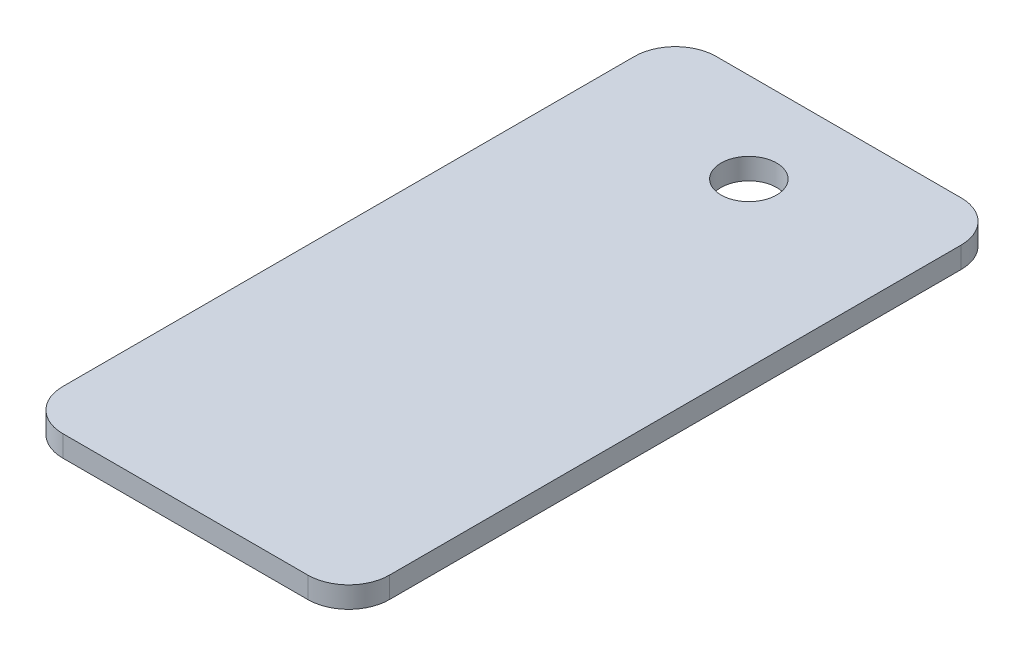
from build123d import *

# Parameters (mm, degrees)
SKETCH1_W                = 20
SKETCH1_H                = 40
BOSS_EXTRUDE1_DEPTH      = 1.3
M3_CLEARANCE_HOLE1_D     = 3.4
M3_CLEARANCE_HOLE1_DEPTH = 1.3
FILLET1_R                = 2.5


with BuildPart() as part:
    # Sketch1 → Boss-Extrude1 (new body)
    with BuildSketch(Plane(origin=(0, 0, 0), x_dir=(1, 0, 0), z_dir=(0, 1, 0))):
        with Locations((10, -20)):
            Rectangle(SKETCH1_W, SKETCH1_H)
    extrude(amount=BOSS_EXTRUDE1_DEPTH)

    # M3 Clearance Hole1
    with Locations(Plane(origin=(0, 1.3, 0), x_dir=(1, 0, 0), z_dir=(0, 1, 0))):
        with Locations((10, -5.5)):
            Hole(M3_CLEARANCE_HOLE1_D / 2, depth=M3_CLEARANCE_HOLE1_DEPTH)

    # Fillet1
    fillet1_edges = [part.edges().sort_by_distance(p)[0] for p in [
        (0, 0.65, 0),
        (20, 0.65, 0),
        (20, 0.65, 40),
        (0, 0.65, 40),
    ]]
    fillet(fillet1_edges, radius=FILLET1_R)


solid = part.part
